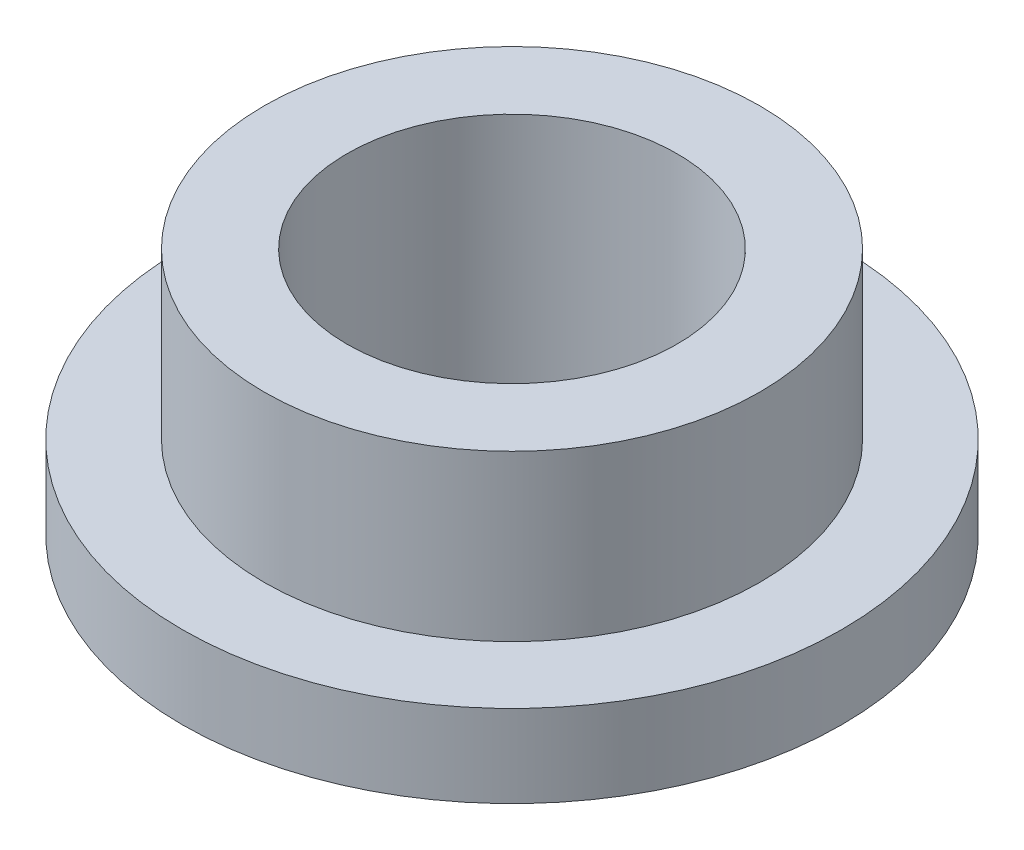
from build123d import *

# Parameters (mm, degrees)
SKETCH2_R           = 6.015
SKETCH2_R_2         = 4.005
BOSS_EXTRUDE1_DEPTH = 6
SKETCH3_R           = 8
SKETCH3_R_2         = 6.015
BOSS_EXTRUDE2_DEPTH = 2


with BuildPart() as part:
    # Sketch2 → Boss-Extrude1 (new body)
    with BuildSketch(Plane(origin=(0, 0, 0), x_dir=(1, 0, 0), z_dir=(0, 1, 0))):
        Circle(SKETCH2_R)
        Circle(SKETCH2_R_2, mode=Mode.SUBTRACT)
    extrude(amount=BOSS_EXTRUDE1_DEPTH)

    # Sketch3 → Boss-Extrude2 (add)
    with BuildSketch(Plane(origin=(0, 0, 0), x_dir=(1, 0, 0), z_dir=(0, 1, 0))):
        Circle(SKETCH3_R)
        Circle(SKETCH3_R_2, mode=Mode.SUBTRACT)
    extrude(amount=BOSS_EXTRUDE2_DEPTH)


solid = part.part
